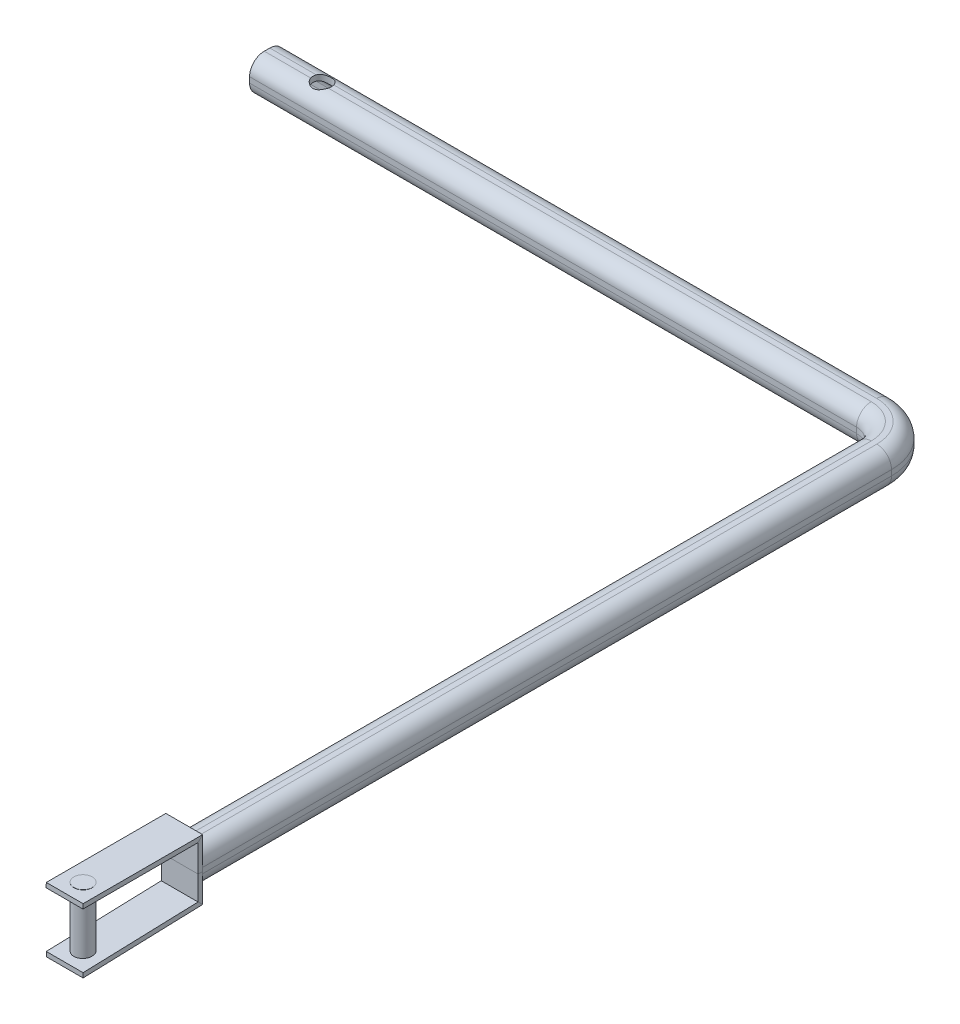
from build123d import *

# Parameters (mm, degrees)
SKETCH4_R                = 5
BOSS_EXTRUDE2_DEPTH      = 17.5
BOSS_EXTRUDE2_DEPTH_BACK = 17.5
SKETCH7_W                = 20
SKETCH7_H                = 2.5
SKETCH8_R                = 5
CUT_EXTRUDE1_DEPTH       = 18.5
CUT_EXTRUDE1_DEPTH_BACK  = 18.6


with BuildPart() as part:
    # Sweep-Thin1: sweep along a path in Sketch1
    with BuildLine(Plane(origin=(0, 0, 0), x_dir=(1, 0, 0), z_dir=(0, 1, 0))) as sweep_thin1_path:
        Line((0, 0), (330, 0))
        ThreePointArc((330, 0), (344.142135624, -5.857864376), (350, -20))
        Line((350, -20), (350, -395))
    # Sketch2 → Sweep-Thin1 (sweep)
    with BuildSketch(Plane(origin=(0, 0, 0), x_dir=(0, 0, -1), z_dir=(1, 0, 0))):
        with BuildLine():
            Line((1.5, 9.5), (-1.5, 9.5))
            ThreePointArc((-1.5, 9.5), (-7.156854249, 7.156854249), (-9.5, 1.5))
            Line((-9.5, 1.5), (-9.5, -1.5))
            ThreePointArc((-9.5, -1.5), (-7.156854249, -7.156854249), (-1.5, -9.5))
            Line((-1.5, -9.5), (1.5, -9.5))
            ThreePointArc((1.5, -9.5), (7.156854249, -7.156854249), (9.5, -1.5))
            Line((9.5, -1.5), (9.5, 1.5))
            ThreePointArc((9.5, 1.5), (7.156854249, 7.156854249), (1.5, 9.5))
        make_face()
        with BuildLine():
            Line((1.5, 6.5), (-1.5, 6.5))
            ThreePointArc((-1.5, 6.5), (-5.035533906, 5.035533906), (-6.5, 1.5))
            Line((-6.5, 1.5), (-6.5, -1.5))
            ThreePointArc((-6.5, -1.5), (-5.035533906, -5.035533906), (-1.5, -6.5))
            Line((-1.5, -6.5), (1.5, -6.5))
            ThreePointArc((1.5, -6.5), (5.035533906, -5.035533906), (6.5, -1.5))
            Line((6.5, -1.5), (6.5, 1.5))
            ThreePointArc((6.5, 1.5), (5.035533906, 5.035533906), (1.5, 6.5))
        make_face(mode=Mode.SUBTRACT)
    sweep(path=sweep_thin1_path.line)



with BuildPart() as body_2:
    # Sketch4 → Boss-Extrude2 (new body, two sides)
    with BuildSketch(Plane(origin=(0, 0, 0), x_dir=(1, 0, 0), z_dir=(0, 1, 0))) as boss_extrude2_sk:
        with Locations((350, -450)):
            Circle(SKETCH4_R)
    extrude(amount=BOSS_EXTRUDE2_DEPTH)
    extrude(boss_extrude2_sk.sketch, amount=-BOSS_EXTRUDE2_DEPTH_BACK)


with BuildPart() as part_1:
    add(part.part)

    add(body_2.part)  # Sweep1 merges body 2
    # Sweep1: sweep along a path in Sketch6
    with BuildLine(Plane(origin=(350, 0, 0), x_dir=(0, 0, -1), z_dir=(1, 0, 0))) as sweep1_path:
        Line((-460, 17.4), (-395, 17.4))
        Line((-395, 17.4), (-395, 0))
        Line((-395, 0), (-395, -15.485164569))
        Line((-395, -15.485164569), (-460, -17.6))
    # Sketch7 → Sweep1 (sweep)
    with BuildSketch(Plane.XY.offset(460)):
        with Locations((350, -16.35)):
            Rectangle(SKETCH7_W, SKETCH7_H)
    sweep(path=sweep1_path.line, transition=Transition.RIGHT)

    # Sketch8 → Cut-Extrude1 (cut, two sides)
    with BuildSketch(Plane(origin=(0, 0, 0), x_dir=(1, 0, 0), z_dir=(0, 1, 0))) as cut_extrude1_sk:
        with Locations((30, 0)):
            Circle(SKETCH8_R)
    extrude(amount=CUT_EXTRUDE1_DEPTH, mode=Mode.SUBTRACT)
    extrude(cut_extrude1_sk.sketch, amount=-CUT_EXTRUDE1_DEPTH_BACK, mode=Mode.SUBTRACT)


solid = part_1.part
